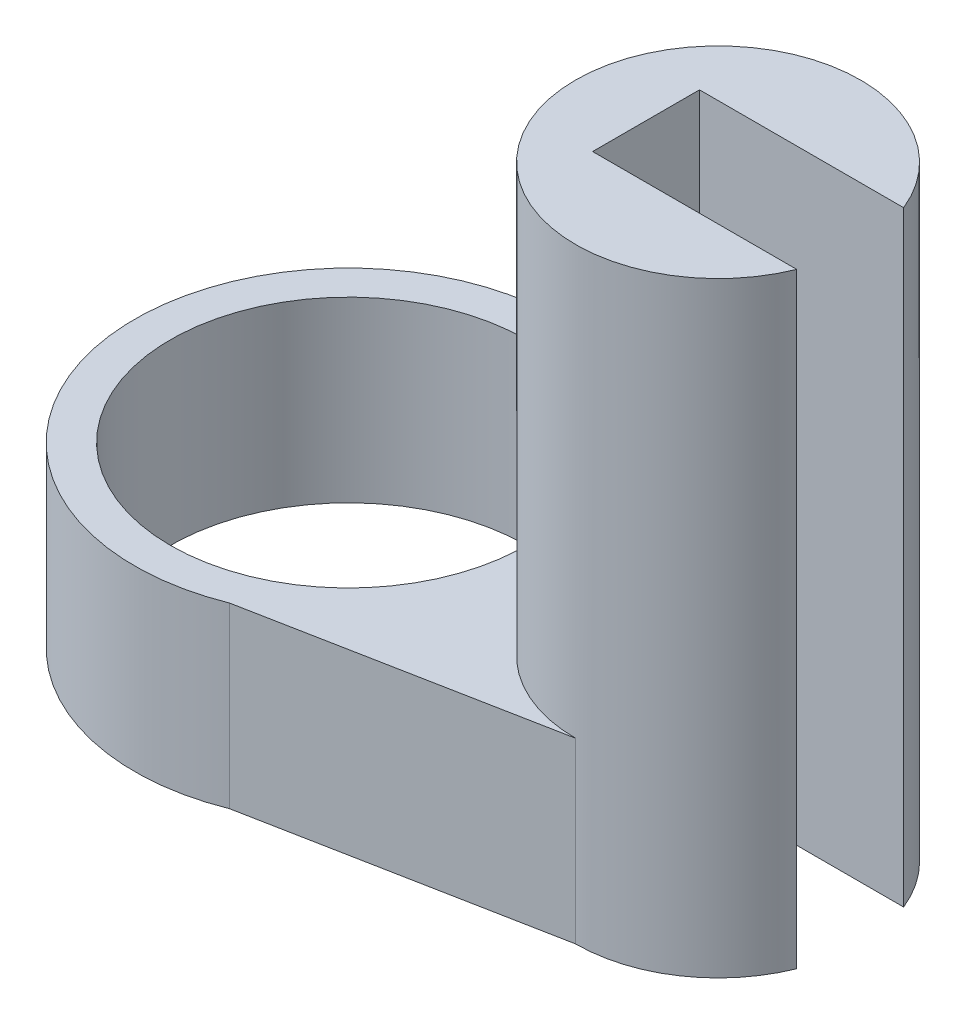
from build123d import *

# Parameters (mm, degrees)
SKETCH_1_R          = 6
EXTRUDE_1_DEPTH     = 5
SKETCH_3_R          = 4
EXTRUDE_2_DEPTH     = 5
EXTRUDE_3_DEPTH     = 5
SKETCH_2_R          = 5
CUT_EXTRUDE_1_DEPTH = 6
SKETCH_5_R          = 4
EXTRUDE_4_DEPTH     = 12
SKETCH_6_W          = 10.625447748
SKETCH_6_H          = 3
CUT_EXTRUDE_2_DEPTH = 18


with BuildPart() as part:
    # 草图1 → 凸台-拉伸1 (new body)
    with BuildSketch(Plane(origin=(0, 0, 0), x_dir=(1, 0, 0), z_dir=(0, 1, 0))):
        Circle(SKETCH_1_R)
    extrude(amount=EXTRUDE_1_DEPTH)



with BuildPart() as body_2:
    # 草图3 → 凸台-拉伸2 (new body)
    with BuildSketch(Plane(origin=(0, 0, 0), x_dir=(1, 0, 0), z_dir=(0, 1, 0))):
        with Locations((10.373073214, 0)):
            Circle(SKETCH_3_R)
    extrude(amount=EXTRUDE_2_DEPTH)


with BuildPart() as part_1:
    add(part.part)

    add(body_2.part)  # 凸台-拉伸3 merges body 2
    # 草图4 → 凸台-拉伸3 (add)
    with BuildSketch(Plane(origin=(0, 0, 0), x_dir=(1, 0, 0), z_dir=(0, 1, 0))):
        Polygon((0, 6), (10.373073214, 4), (10.373073214, -4), (0, -6), align=None)
    extrude(amount=EXTRUDE_3_DEPTH)

    # 草图2 → 切除-拉伸1 (cut, through all)
    with BuildSketch(Plane(origin=(0, 5, 0), x_dir=(1, 0, 0), z_dir=(0, 1, 0))):
        Circle(SKETCH_2_R)
    extrude(amount=-CUT_EXTRUDE_1_DEPTH, mode=Mode.SUBTRACT)

    # 草图5 → 凸台-拉伸4 (add)
    with BuildSketch(Plane(origin=(0, 5, 0), x_dir=(1, 0, 0), z_dir=(0, 1, 0))):
        with Locations((10.373073214, 0)):
            Circle(SKETCH_5_R)
    extrude(amount=EXTRUDE_4_DEPTH)

    # 草图6 → 切除-拉伸2 (cut, through all)
    with BuildSketch(Plane(origin=(0, 17, 0), x_dir=(1, 0, 0), z_dir=(0, 1, 0))):
        with Locations((13.66467232, 0)):
            Rectangle(SKETCH_6_W, SKETCH_6_H)
    extrude(amount=-CUT_EXTRUDE_2_DEPTH, mode=Mode.SUBTRACT)


solid = part_1.part
